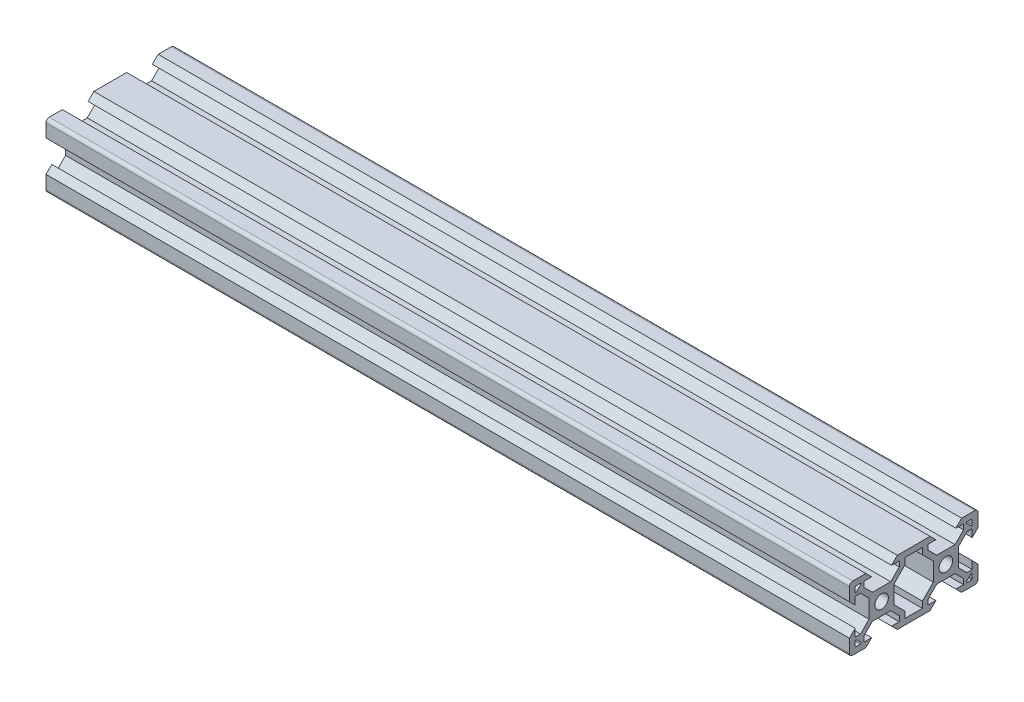
from build123d import *

# Parameters (mm, degrees)
SKETCH5_R           = 2.1
BOSS_EXTRUDE1_DEPTH = 125


with BuildPart() as part:
    # Sketch5 → Boss-Extrude1 (new body, symmetric)
    with BuildSketch(Plane(origin=(0, 0, 0), x_dir=(0, 0, -1), z_dir=(1, 0, 0))):
        with BuildLine():
            Line((-19.998019485, 4.9), (-18.198019485, 3.1))
            Line((-18.198019485, 3.1), (-18.198019485, 5.499339828))
            Line((-18.198019485, 5.499339828), (-16.558019485, 5.499339828))
            Line((-16.558019485, 5.499339828), (-13.9, 2.841320344))
            Line((-13.9, 2.841320344), (-13.9, -2.838679656))
            Line((-13.9, -2.838679656), (-16.558019485, -5.496699141))
            Line((-16.558019485, -5.496699141), (-18.198019485, -5.496699141))
            Line((-18.198019485, -5.496699141), (-18.198019485, -3.1))
            Line((-18.198019485, -3.1), (-19.998019485, -4.9))
            Line((-19.998019485, -4.9), (-19.998019485, -9))
            ThreePointArc((-19.998019485, -9), (-19.705126266, -9.707106781), (-18.998019485, -10))
            Line((-18.998019485, -10), (-14.9, -10))
            Line((-14.9, -10), (-13.1, -8.2))
            Line((-13.1, -8.2), (-15.5, -8.2))
            Line((-15.5, -8.2), (-15.5, -6.56))
            Line((-15.5, -6.56), (-12.84, -3.9))
            Line((-12.84, -3.9), (-7.16, -3.9))
            Line((-7.16, -3.9), (-4.5, -6.56))
            Line((-4.5, -6.56), (-4.5, -8.2))
            Line((-4.5, -8.2), (-6.9, -8.2))
            Line((-6.9, -8.2), (-5.1, -10))
            Line((-5.1, -10), (5.1, -10))
            Line((5.1, -10), (6.9, -8.2))
            Line((6.9, -8.2), (4.496038969, -8.2))
            Line((4.496038969, -8.2), (4.496038969, -6.56))
            Line((4.496038969, -6.56), (7.156038969, -3.9))
            Line((7.156038969, -3.9), (12.836038969, -3.9))
            Line((12.836038969, -3.9), (15.496038969, -6.56))
            Line((15.496038969, -6.56), (15.496038969, -8.2))
            Line((15.496038969, -8.2), (13.1, -8.2))
            Line((13.1, -8.2), (14.9, -10))
            Line((14.9, -10), (19.001980515, -10))
            ThreePointArc((19.001980515, -10), (19.709087297, -9.707106781), (20.001980515, -9))
            Line((20.001980515, -9), (20.001980515, -4.9))
            Line((20.001980515, -4.9), (18.201980515, -3.1))
            Line((18.201980515, -3.1), (18.201980515, -5.504621202))
            Line((18.201980515, -5.504621202), (16.561980515, -5.504621202))
            Line((16.561980515, -5.504621202), (13.9, -2.842640687))
            Line((13.9, -2.842640687), (13.9, 2.837359313))
            Line((13.9, 2.837359313), (16.561980515, 5.499339828))
            Line((16.561980515, 5.499339828), (18.201980515, 5.499339828))
            Line((18.201980515, 5.499339828), (18.201980515, 3.1))
            Line((18.201980515, 3.1), (20.001980515, 4.9))
            Line((20.001980515, 4.9), (20.001980515, 9))
            ThreePointArc((20.001980515, 9), (19.709087297, 9.707106781), (19.001980515, 10))
            Line((19.001980515, 10), (14.9, 10))
            Line((14.9, 10), (13.1, 8.2))
            Line((13.1, 8.2), (15.501320344, 8.2))
            Line((15.501320344, 8.2), (15.501320344, 6.56))
            Line((15.501320344, 6.56), (12.841320344, 3.9))
            Line((12.841320344, 3.9), (7.161320344, 3.9))
            Line((7.161320344, 3.9), (4.501320344, 6.56))
            Line((4.501320344, 6.56), (4.501320344, 8.2))
            Line((4.501320344, 8.2), (6.9, 8.2))
            Line((6.9, 8.2), (5.1, 10))
            Line((5.1, 10), (-5.1, 10))
            Line((-5.1, 10), (-6.9, 8.2))
            Line((-6.9, 8.2), (-4.501320344, 8.2))
            Line((-4.501320344, 8.2), (-4.501320344, 6.56))
            Line((-4.501320344, 6.56), (-7.161320344, 3.9))
            Line((-7.161320344, 3.9), (-12.841320344, 3.9))
            Line((-12.841320344, 3.9), (-15.501320344, 6.56))
            Line((-15.501320344, 6.56), (-15.501320344, 8.2))
            Line((-15.501320344, 8.2), (-13.1, 8.2))
            Line((-13.1, 8.2), (-14.9, 10))
            Line((-14.9, 10), (-18.998019485, 10))
            ThreePointArc((-18.998019485, 10), (-19.705126266, 9.707106781), (-19.998019485, 9))
            Line((-19.998019485, 9), (-19.998019485, 4.9))
        make_face()
        with Locations((-10, 0)):
            Circle(SKETCH5_R, mode=Mode.SUBTRACT)
        with Locations((10, 0)):
            Circle(SKETCH5_R, mode=Mode.SUBTRACT)
        Polygon((6.1, -2.84), (6.1, 2.84), (2.7, 6.24), (2.7, 8.2), (-2.7, 8.2), (-2.7, 6.24), (-6.1, 2.84), (-6.1, -2.84), (-2.7, -6.24), (-2.7, -8.2), (2.7, -8.2), (2.7, -6.24), align=None, mode=Mode.SUBTRACT)
        with BuildLine():
            Line((16.571320344, 8.2), (18.001980515, 8.2))
            ThreePointArc((18.001980515, 8.2), (18.143401872, 8.141421356), (18.201980515, 8))
            Line((18.201980515, 8), (18.201980515, 6.569339828))
            ThreePointArc((18.201980515, 6.569339828), (18.078517202, 6.384563922), (17.860559159, 6.427918472))
            Line((17.860559159, 6.427918472), (16.429898987, 7.858578644))
            ThreePointArc((16.429898987, 7.858578644), (16.386544437, 8.076536686), (16.571320344, 8.2))
        make_face(mode=Mode.SUBTRACT)
        with BuildLine():
            Line((16.571320344, -8.2), (18.001980515, -8.2))
            ThreePointArc((18.001980515, -8.2), (18.143401872, -8.141421356), (18.201980515, -8))
            Line((18.201980515, -8), (18.201980515, -6.569339828))
            ThreePointArc((18.201980515, -6.569339828), (18.078517202, -6.384563922), (17.860559159, -6.427918472))
            Line((17.860559159, -6.427918472), (16.429898987, -7.858578644))
            ThreePointArc((16.429898987, -7.858578644), (16.386544437, -8.076536686), (16.571320344, -8.2))
        make_face(mode=Mode.SUBTRACT)
        with BuildLine():
            Line((-17.860559159, 6.427918472), (-16.429898987, 7.858578644))
            ThreePointArc((-16.429898987, 7.858578644), (-16.386544437, 8.076536686), (-16.571320344, 8.2))
            Line((-16.571320344, 8.2), (-18.001980515, 8.2))
            ThreePointArc((-18.001980515, 8.2), (-18.143401872, 8.141421356), (-18.201980515, 8))
            Line((-18.201980515, 8), (-18.201980515, 6.569339828))
            ThreePointArc((-18.201980515, 6.569339828), (-18.078517202, 6.384563922), (-17.860559159, 6.427918472))
        make_face(mode=Mode.SUBTRACT)
        with BuildLine():
            Line((-16.571320344, -8.2), (-18.001980515, -8.2))
            ThreePointArc((-18.001980515, -8.2), (-18.143401872, -8.141421356), (-18.201980515, -8))
            Line((-18.201980515, -8), (-18.201980515, -6.569339828))
            ThreePointArc((-18.201980515, -6.569339828), (-18.078517202, -6.384563922), (-17.860559159, -6.427918472))
            Line((-17.860559159, -6.427918472), (-16.429898987, -7.858578644))
            ThreePointArc((-16.429898987, -7.858578644), (-16.386544437, -8.076536686), (-16.571320344, -8.2))
        make_face(mode=Mode.SUBTRACT)
    extrude(amount=BOSS_EXTRUDE1_DEPTH, both=True)


solid = part.part
